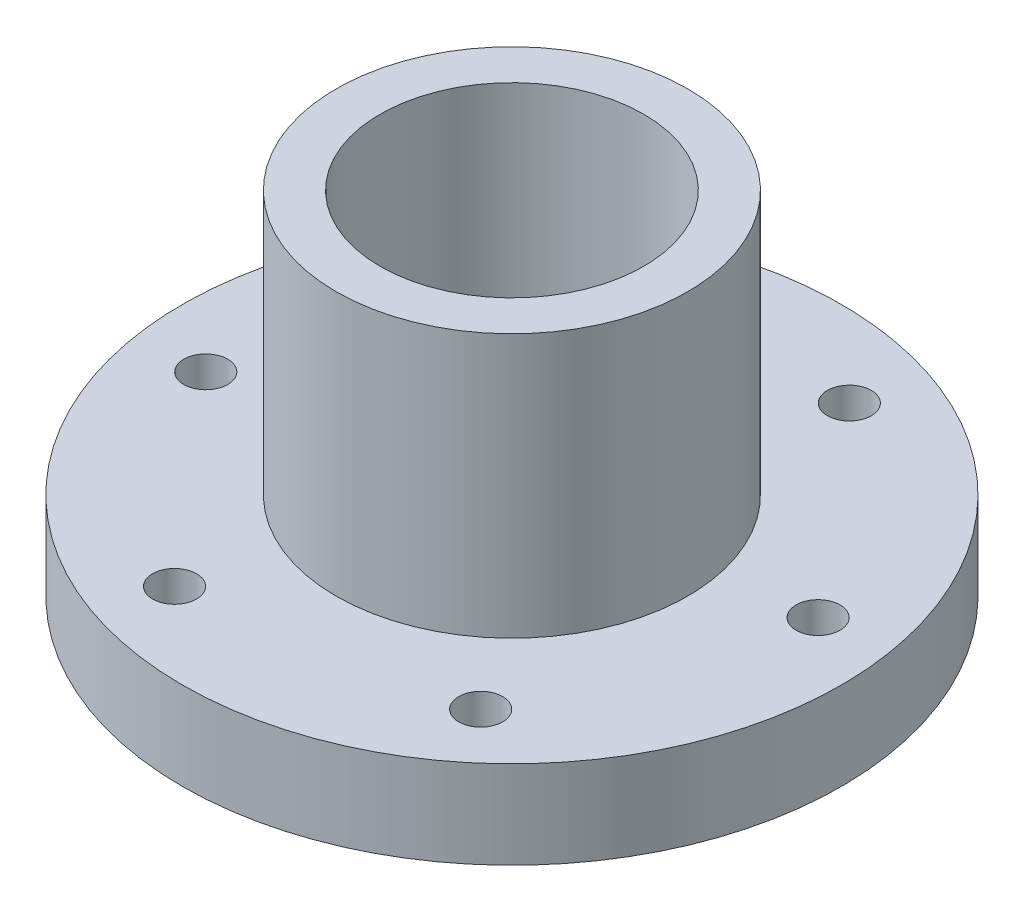
from build123d import *

# Parameters (mm, degrees)
F_1_8_0_125_DIAMETER_HOLE1_D = 3.175


with BuildPart() as part:
    # Sketch1 → Revolve1 (revolve)
    with BuildSketch(Plane.XY):
        Polygon((0.150394737, -4.879473684), (-14.137105263, -4.879473684), (-14.137105263, 1.470526316), (-3.024605263, 1.470526316), (-3.024605263, 20.520526316), (0.150394737, 20.520526316), align=None)
    revolve(axis=Axis((9.675394737, 1.470526316, 0), (0, -1, 0)))

    # 1/8 (0.125) Diameter Hole1 (through all)
    with Locations(Plane(origin=(0, 1.470526316, 0), x_dir=(1, 0, 0), z_dir=(0, 1, 0))):
        with Locations((3.220899988, -17.923225088), (-9.073820881, -3.371856123), (-2.619326132, 14.551368965), (16.129889486, 17.923225088), (28.424610355, 3.371856123), (21.970115606, -14.551368965), (9.675394737, 0)):
            Hole(F_1_8_0_125_DIAMETER_HOLE1_D / 2)


solid = part.part
